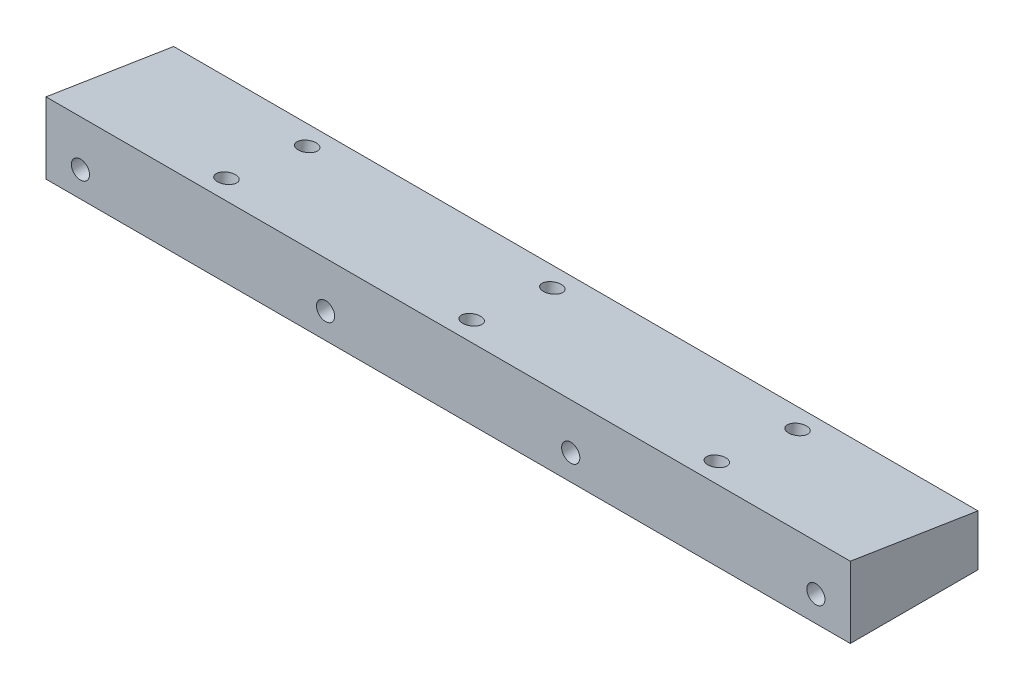
from build123d import *

# Parameters (mm, degrees)
SKETCH1_W             = 100
SKETCH1_H             = 6.35
BOSS_EXTRUDE1_DEPTH   = 15.875
F_4_40_TAPPED_HOLE1_D = 2.2606
BOSS_EXTRUDE2_DEPTH   = 100
F_4_40_TAPPED_HOLE2_D = 2.2606


with BuildPart() as part:
    # Sketch1 → Boss-Extrude1 (new body)
    with BuildSketch(Plane.XY):
        with Locations((50, -3.175)):
            Rectangle(SKETCH1_W, SKETCH1_H)
    extrude(amount=BOSS_EXTRUDE1_DEPTH)

    # 4-40 Tapped Hole1 (through all)
    with Locations(Plane(origin=(0, 0, 0), x_dir=(-1, 0, 0), z_dir=(0, 0, -1))):
        with Locations((-95.72, -3.175), (-4.28, -3.175), (-34.76, -3.175), (-65.24, -3.175)):
            Hole(F_4_40_TAPPED_HOLE1_D / 2)

    # Sketch4 → Boss-Extrude2 (add, through all)
    with BuildSketch(Plane(origin=(100, 0, 0), x_dir=(0, 0, -1), z_dir=(1, 0, 0))):
        Polygon((0, 0), (-15.875, 2.51435299), (-15.875, 0), align=None)
    extrude(amount=-BOSS_EXTRUDE2_DEPTH)

    # 4-40 Tapped Hole2 (through all)
    with Locations(Plane(origin=(0, 0, 0), x_dir=(1, 0, 0), z_dir=(0, 0.987688341, -0.156434465))):
        with Locations((80.48, -13.116441936), (80.48, -2.956441936), (50, -13.116441936), (50, -2.956441936), (19.52, -13.116441936), (19.52, -2.956441936)):
            Hole(F_4_40_TAPPED_HOLE2_D / 2)


solid = part.part
